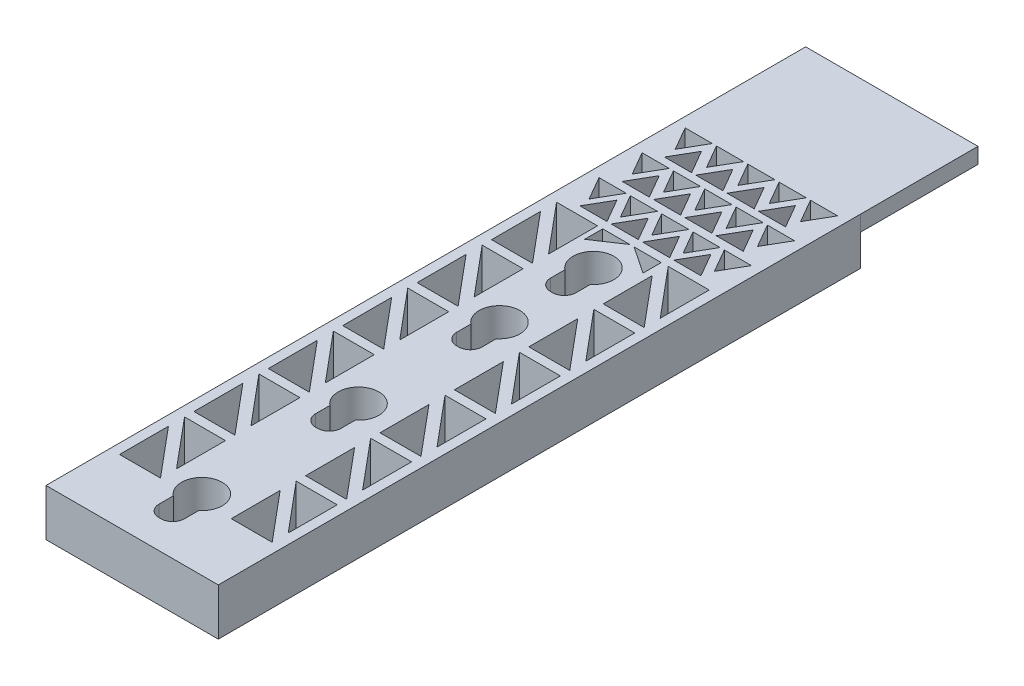
from build123d import *

# Parameters (mm, degrees)
SKETCH23_W             = 22
SKETCH23_H             = 82
SKETCH23_R             = 2.6
BOSS_EXTRUDE3_DEPTH    = 6
SKETCH25_W             = 3.25
SKETCH25_H             = 5.5
CUT_EXTRUDE1_DEPTH     = 15.321988807
FILLET1_R              = 1.5
FILLET2_R              = 1.5
CUT_EXTRUDE7_DEPTH     = 13.794769433
LPATTERN3_COUNT        = 3
LPATTERN3_PITCH        = 4
LPATTERN3_COL_COUNT    = 3
LPATTERN3_COL_PITCH    = 4
LPATTERN4_COUNT        = 3
LPATTERN4_PITCH        = 5.5
LPATTERN4_COPY_1_DEPTH = 13.794769433
LPATTERN4_COPY_2_DEPTH = 13.794769433
LPATTERN4_COPY_3_DEPTH = 13.794769433
LPATTERN4_COPY_4_DEPTH = 13.794769433
LPATTERN4_COPY_5_DEPTH = 13.794769433
LPATTERN4_COPY_6_DEPTH = 13.794769433
LPATTERN4_COPY_7_DEPTH = 13.794769433
LPATTERN4_COPY_8_DEPTH = 13.794769433
CUT_EXTRUDE8_DEPTH     = 13.484872428
LPATTERN5_COUNT        = 4
LPATTERN5_PITCH        = 4
LPATTERN5_COUNT_DIR2   = 3
LPATTERN5_PITCH_DIR2   = 5.4
CUT_EXTRUDE9_DEPTH     = 53.672312212
LPATTERN7_COUNT        = 6
LPATTERN7_PITCH        = 9.5
CUT_EXTRUDE10_DEPTH    = 24.803748702
LPATTERN8_COUNT        = 6
LPATTERN8_PITCH        = 9.5
CUT_EXTRUDE11_DEPTH    = 27.40661391
LPATTERN9_COUNT        = 6
LPATTERN9_PITCH        = 9.5
CUT_EXTRUDE12_DEPTH    = 18.752181215
LPATTERN10_COUNT       = 6
LPATTERN10_PITCH       = 9.5
CUT_EXTRUDE13_DEPTH    = 6
SKETCH42_W             = 22.003595265
SKETCH42_H             = 15
BOSS_EXTRUDE4_DEPTH    = 2
BOSS_EXTRUDE5_DEPTH    = 4


with BuildPart() as part:
    # Sketch23 → Boss-Extrude3 (new body)
    with BuildSketch(Plane(origin=(0, 0, 0), x_dir=(1, 0, 0), z_dir=(0, 1, 0))):
        with Locations((192.096404735, -41)):
            Rectangle(SKETCH23_W, SKETCH23_H)
        with Locations((192, -73)):
            Circle(SKETCH23_R, mode=Mode.SUBTRACT)
        with Locations((192, -53)):
            Circle(SKETCH23_R, mode=Mode.SUBTRACT)
        with Locations((192, -35)):
            Circle(SKETCH23_R, mode=Mode.SUBTRACT)
        with Locations((192, -23)):
            Circle(SKETCH23_R, mode=Mode.SUBTRACT)
    extrude(amount=-BOSS_EXTRUDE3_DEPTH)

    # Sketch25 → Cut-Extrude1 (cut)
    with BuildSketch(Plane(origin=(0, 0, 0), x_dir=(1, 0, 0), z_dir=(0, 1, 0))):
        with Locations((192, -75.6)):
            Rectangle(SKETCH25_W, SKETCH25_H)
        with Locations((192, -55.6)):
            Rectangle(SKETCH25_W, SKETCH25_H)
        with Locations((192, -37.6)):
            Rectangle(SKETCH25_W, SKETCH25_H)
        with Locations((192, -25.6)):
            Rectangle(SKETCH25_W, SKETCH25_H)
    extrude(amount=-CUT_EXTRUDE1_DEPTH, mode=Mode.SUBTRACT)

    # Fillet1
    fillet1_edges = [part.edges().sort_by_distance(p)[0] for p in [
        (193.625, -3, 78.35),
        (190.375, -3, 78.35),
        (193.625, -3, 40.35),
        (190.375, -3, 40.35),
        (193.625, -3, 28.35),
        (190.375, -3, 28.35),
    ]]
    fillet(fillet1_edges, radius=FILLET1_R)

    # Fillet2
    fillet2_edges = [part.edges().sort_by_distance(p)[0] for p in [
        (193.625, -3, 58.35),
        (190.375, -3, 58.35),
    ]]
    fillet(fillet2_edges, radius=FILLET2_R)

    # Sketch30 → Cut-Extrude7 (cut)
    with BuildSketch(Plane(origin=(0, 0, 0), x_dir=(1, 0, 0), z_dir=(0, 1, 0))):
        Polygon((192.096404735, -4.654849334), (193.828455542, -1.654849334), (190.364353927, -1.654849334), align=None)
    cut_extrude7 = extrude(amount=-CUT_EXTRUDE7_DEPTH, mode=Mode.SUBTRACT)

    # LPattern3: Cut-Extrude7 ×3
    with Locations(*[(-i * LPATTERN3_PITCH, 0, 0) for i in range(1, LPATTERN3_COUNT)]):
        add(cut_extrude7, mode=Mode.SUBTRACT)

    # LPattern3 col: Cut-Extrude7 ×3
    with Locations(*[(i * LPATTERN3_COL_PITCH, 0, 0) for i in range(1, LPATTERN3_COL_COUNT)]):
        add(cut_extrude7, mode=Mode.SUBTRACT)

    # LPattern4: Cut-Extrude7 ×3
    with Locations(*[(0, 0, i * LPATTERN4_PITCH) for i in range(1, LPATTERN4_COUNT)]):
        add(cut_extrude7, mode=Mode.SUBTRACT)

    # LPattern4 copy 1 sketch → LPattern4 copy 1 (cut)
    with BuildSketch(Plane(origin=(-4, 0, 5.5), x_dir=(1, 0, 0), z_dir=(0, 1, 0))):
        Polygon((192.096404735, -4.654849334), (193.828455542, -1.654849334), (190.364353927, -1.654849334), align=None)
    extrude(amount=-LPATTERN4_COPY_1_DEPTH, mode=Mode.SUBTRACT)

    # LPattern4 copy 2 sketch → LPattern4 copy 2 (cut)
    with BuildSketch(Plane(origin=(-4, 0, 11), x_dir=(1, 0, 0), z_dir=(0, 1, 0))):
        Polygon((192.096404735, -4.654849334), (193.828455542, -1.654849334), (190.364353927, -1.654849334), align=None)
    extrude(amount=-LPATTERN4_COPY_2_DEPTH, mode=Mode.SUBTRACT)

    # LPattern4 copy 3 sketch → LPattern4 copy 3 (cut)
    with BuildSketch(Plane(origin=(-8, 0, 5.5), x_dir=(1, 0, 0), z_dir=(0, 1, 0))):
        Polygon((192.096404735, -4.654849334), (193.828455542, -1.654849334), (190.364353927, -1.654849334), align=None)
    extrude(amount=-LPATTERN4_COPY_3_DEPTH, mode=Mode.SUBTRACT)

    # LPattern4 copy 4 sketch → LPattern4 copy 4 (cut)
    with BuildSketch(Plane(origin=(-8, 0, 11), x_dir=(1, 0, 0), z_dir=(0, 1, 0))):
        Polygon((192.096404735, -4.654849334), (193.828455542, -1.654849334), (190.364353927, -1.654849334), align=None)
    extrude(amount=-LPATTERN4_COPY_4_DEPTH, mode=Mode.SUBTRACT)

    # LPattern4 copy 5 sketch → LPattern4 copy 5 (cut)
    with BuildSketch(Plane(origin=(4, 0, 5.5), x_dir=(1, 0, 0), z_dir=(0, 1, 0))):
        Polygon((192.096404735, -4.654849334), (193.828455542, -1.654849334), (190.364353927, -1.654849334), align=None)
    extrude(amount=-LPATTERN4_COPY_5_DEPTH, mode=Mode.SUBTRACT)

    # LPattern4 copy 6 sketch → LPattern4 copy 6 (cut)
    with BuildSketch(Plane(origin=(4, 0, 11), x_dir=(1, 0, 0), z_dir=(0, 1, 0))):
        Polygon((192.096404735, -4.654849334), (193.828455542, -1.654849334), (190.364353927, -1.654849334), align=None)
    extrude(amount=-LPATTERN4_COPY_6_DEPTH, mode=Mode.SUBTRACT)

    # LPattern4 copy 7 sketch → LPattern4 copy 7 (cut)
    with BuildSketch(Plane(origin=(8, 0, 5.5), x_dir=(1, 0, 0), z_dir=(0, 1, 0))):
        Polygon((192.096404735, -4.654849334), (193.828455542, -1.654849334), (190.364353927, -1.654849334), align=None)
    extrude(amount=-LPATTERN4_COPY_7_DEPTH, mode=Mode.SUBTRACT)

    # LPattern4 copy 8 sketch → LPattern4 copy 8 (cut)
    with BuildSketch(Plane(origin=(8, 0, 11), x_dir=(1, 0, 0), z_dir=(0, 1, 0))):
        Polygon((192.096404735, -4.654849334), (193.828455542, -1.654849334), (190.364353927, -1.654849334), align=None)
    extrude(amount=-LPATTERN4_COPY_8_DEPTH, mode=Mode.SUBTRACT)

    # Sketch31 → Cut-Extrude8 (cut)
    with BuildSketch(Plane(origin=(0, 0, 0), x_dir=(1, 0, 0), z_dir=(0, 1, 0))):
        Polygon((185.996404735, -3.2), (184.264353927, -6.2), (187.728455542, -6.2), align=None)
    cut_extrude8 = extrude(amount=-CUT_EXTRUDE8_DEPTH, mode=Mode.SUBTRACT)

    # LPattern5: Cut-Extrude8 4 × 3
    with Locations(*[(i * LPATTERN5_PITCH, 0, j * LPATTERN5_PITCH_DIR2) for i in range(LPATTERN5_COUNT) for j in range(LPATTERN5_COUNT_DIR2) if (i, j) != (0, 0)]):
        add(cut_extrude8, mode=Mode.SUBTRACT)

    # Sketch33 → Cut-Extrude9 (cut)
    with BuildSketch(Plane(origin=(0, 0, 0), x_dir=(1, 0, 0), z_dir=(0, 1, 0))):
        Polygon((201.826404735, -18.05), (196.596404735, -18.05), (201.826404735, -24.302849063), align=None)
    cut_extrude9 = extrude(amount=-CUT_EXTRUDE9_DEPTH, mode=Mode.SUBTRACT)

    # LPattern7: Cut-Extrude9 ×6
    with Locations(*[(0, 0, i * LPATTERN7_PITCH) for i in range(1, LPATTERN7_COUNT)]):
        add(cut_extrude9, mode=Mode.SUBTRACT)

    # Sketch38 → Cut-Extrude10 (cut)
    with BuildSketch(Plane(origin=(0, 0, 0), x_dir=(1, 0, 0), z_dir=(0, 1, 0))):
        Polygon((187.596404735, -18.08), (182.366404735, -18.08), (187.596404735, -24.332849063), align=None)
    cut_extrude10 = extrude(amount=-CUT_EXTRUDE10_DEPTH, mode=Mode.SUBTRACT)

    # LPattern8: Cut-Extrude10 ×6
    with Locations(*[(0, 0, i * LPATTERN8_PITCH) for i in range(1, LPATTERN8_COUNT)]):
        add(cut_extrude10, mode=Mode.SUBTRACT)

    # Sketch39 → Cut-Extrude11 (cut)
    with BuildSketch(Plane(origin=(0, 0, 0), x_dir=(1, 0, 0), z_dir=(0, 1, 0))):
        Polygon((201.826404735, -26.35), (196.596404735, -20.1), (196.596404735, -26.35), align=None)
    cut_extrude11 = extrude(amount=-CUT_EXTRUDE11_DEPTH, mode=Mode.SUBTRACT)

    # LPattern9: Cut-Extrude11 ×6
    with Locations(*[(0, 0, i * LPATTERN9_PITCH) for i in range(1, LPATTERN9_COUNT)]):
        add(cut_extrude11, mode=Mode.SUBTRACT)

    # Sketch40 → Cut-Extrude12 (cut)
    with BuildSketch(Plane(origin=(0, 0, 0), x_dir=(1, 0, 0), z_dir=(0, 1, 0))):
        Polygon((187.596404735, -26.38), (182.366404735, -20.13), (182.366404735, -26.38), align=None)
    cut_extrude12 = extrude(amount=-CUT_EXTRUDE12_DEPTH, mode=Mode.SUBTRACT)

    # LPattern10: Cut-Extrude12 ×6
    with Locations(*[(0, 0, i * LPATTERN10_PITCH) for i in range(1, LPATTERN10_COUNT)]):
        add(cut_extrude12, mode=Mode.SUBTRACT)

    # Sketch41 → Cut-Extrude13 (cut)
    with BuildSketch(Plane(origin=(0, 0, 0), x_dir=(1, 0, 0), z_dir=(0, 1, 0))):
        Polygon((188.264353927, -18.08), (191.728455542, -18.08), (188.264353927, -20.4), align=None)
        Polygon((195.728455542, -18.08), (192.264353927, -18.08), (195.728455542, -20.4), align=None)
    extrude(amount=-CUT_EXTRUDE13_DEPTH, mode=Mode.SUBTRACT)

    # Sketch42 → Boss-Extrude4 (add)
    with BuildSketch(Plane(origin=(0, 0, 0), x_dir=(1, 0, 0), z_dir=(0, 1, 0))):
        with Locations((192.098202368, 7.5)):
            Rectangle(SKETCH42_W, SKETCH42_H)
    extrude(amount=-BOSS_EXTRUDE4_DEPTH)

    # Sketch48 → Boss-Extrude5 (add)
    with BuildSketch(Plane.XZ.offset(2)):
        Polygon((186.096404735, -4), (198.1, -4), (198.1, -8), (195.1, -8), (195.1, -12), (189.096404735, -12), (189.096404735, -8), (186.096404735, -8), align=None)
    extrude(amount=BOSS_EXTRUDE5_DEPTH)


solid = part.part
